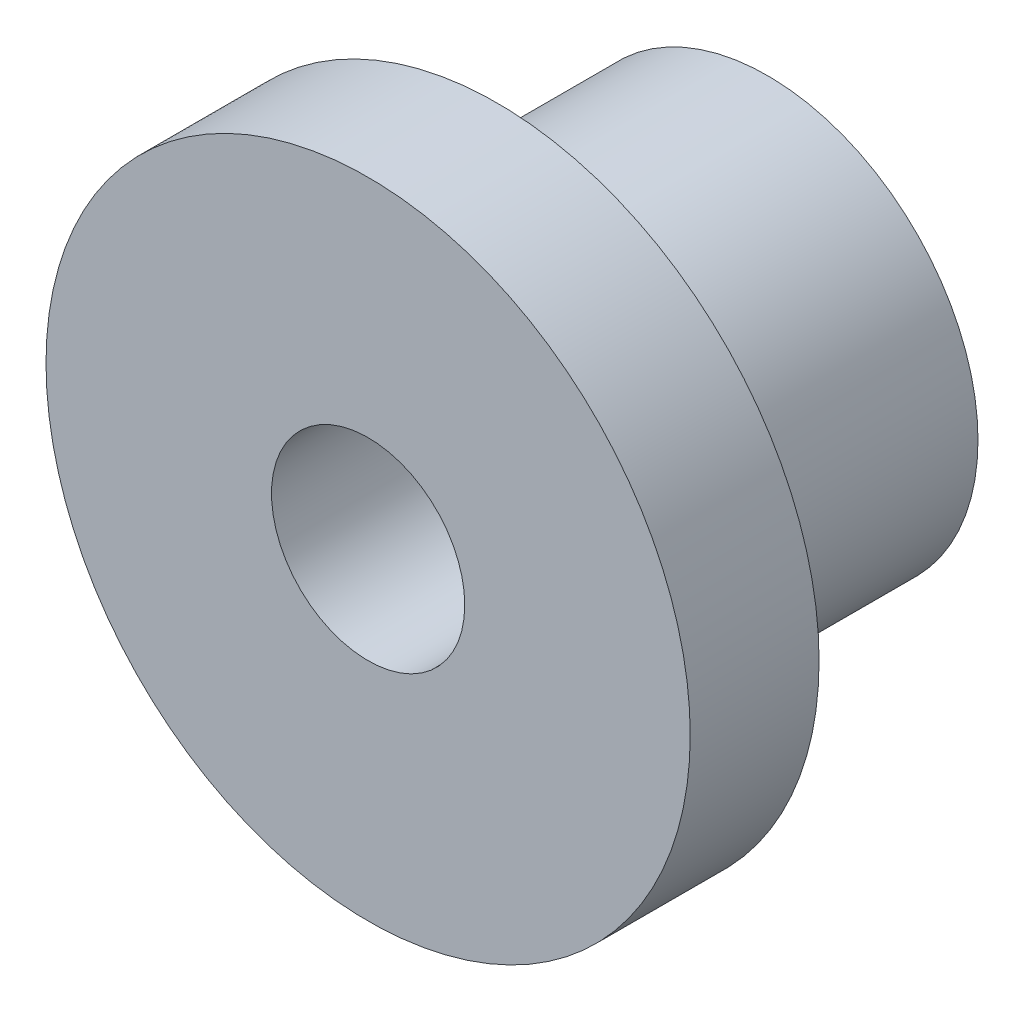
from build123d import *

# Parameters (mm, degrees)
SKETCH1_R           = 4.9
SKETCH1_R_2         = 2.25
BOSS_EXTRUDE1_DEPTH = 3.15
SKETCH2_R           = 7.5
SKETCH2_R_2         = 2.25
BOSS_EXTRUDE2_DEPTH = 3


with BuildPart() as part:
    # Sketch1 → Boss-Extrude1 (new body, symmetric)
    with BuildSketch(Plane.XY):
        Circle(SKETCH1_R)
        Circle(SKETCH1_R_2, mode=Mode.SUBTRACT)
    extrude(amount=BOSS_EXTRUDE1_DEPTH, both=True)

    # Sketch2 → Boss-Extrude2 (add)
    with BuildSketch(Plane.XY.offset(3.15)):
        Circle(SKETCH2_R)
        Circle(SKETCH2_R_2, mode=Mode.SUBTRACT)
    extrude(amount=BOSS_EXTRUDE2_DEPTH)


solid = part.part
